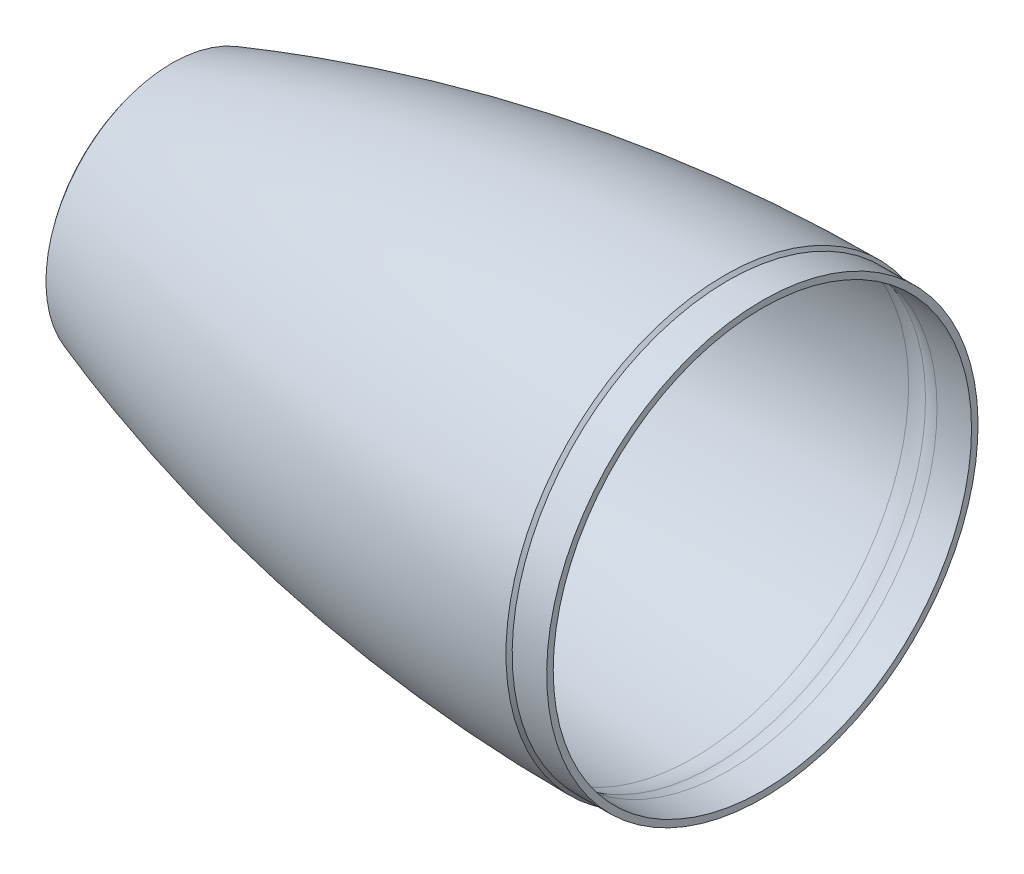
from build123d import *

# Parameters (mm, degrees)
FILLET1_R           = 3.175
BOSS_EXTRUDE1_START = 1.27
SKETCH2_R           = 44.7325
SKETCH2_R_2         = 44.1325
BOSS_EXTRUDE1_DEPTH = 1.27


with BuildPart() as part:
    # Sketch1 → Revolve1 (revolve)
    with BuildSketch(Plane.XY):
        with BuildLine():
            Line((1.143, 79.375), (13.843, 79.375))
            Line((13.843, 79.375), (13.843, 76.975))
            Line((13.843, 76.975), (1.143, 76.975))
            ThreePointArc((1.143, 76.975), (-1.493261461, 77.212559303), (-4.044584679, 77.917583239))
            ThreePointArc((-4.044584679, 77.917583239), (-7.739504947, 78.920164754), (-11.557, 79.210573098))
            ThreePointArc((-11.557, 79.210573098), (-104.887907305, 70.40631157), (-195.834, 47.669084324))
            Line((-195.834, 47.669084324), (-199.644, 44.1325))
            Line((-199.644, 44.1325), (-203.454, 44.1325))
            Line((-203.454, 44.1325), (-203.454, 46.355))
            ThreePointArc((-203.454, 46.355), (-103.15115206, 71.917881411), (0, 80.518))
            Line((0, 80.518), (1.143, 79.375))
        make_face()
    revolve(axis=Axis((0, 0, 0), (-1, 0, 0)))

    # Fillet1
    fillet1_edges = [part.edges().sort_by_distance(p)[0] for p in [
        (-195.834, -47.669084324, 0),
        (-199.644, -44.1325, 0),
    ]]
    fillet(fillet1_edges, radius=FILLET1_R)

    # Sketch2 → Boss-Extrude1 (add)
    with BuildSketch(Plane.ZY.offset(203.454).offset(BOSS_EXTRUDE1_START)):
        with Locations(Location((0, 0, 0), (0, 0, 270))):
            Circle(SKETCH2_R)
        with Locations(Location((0, 0, 0), (0, 0, 270))):
            Circle(SKETCH2_R_2, mode=Mode.SUBTRACT)
    extrude(amount=-BOSS_EXTRUDE1_DEPTH)


solid = part.part
